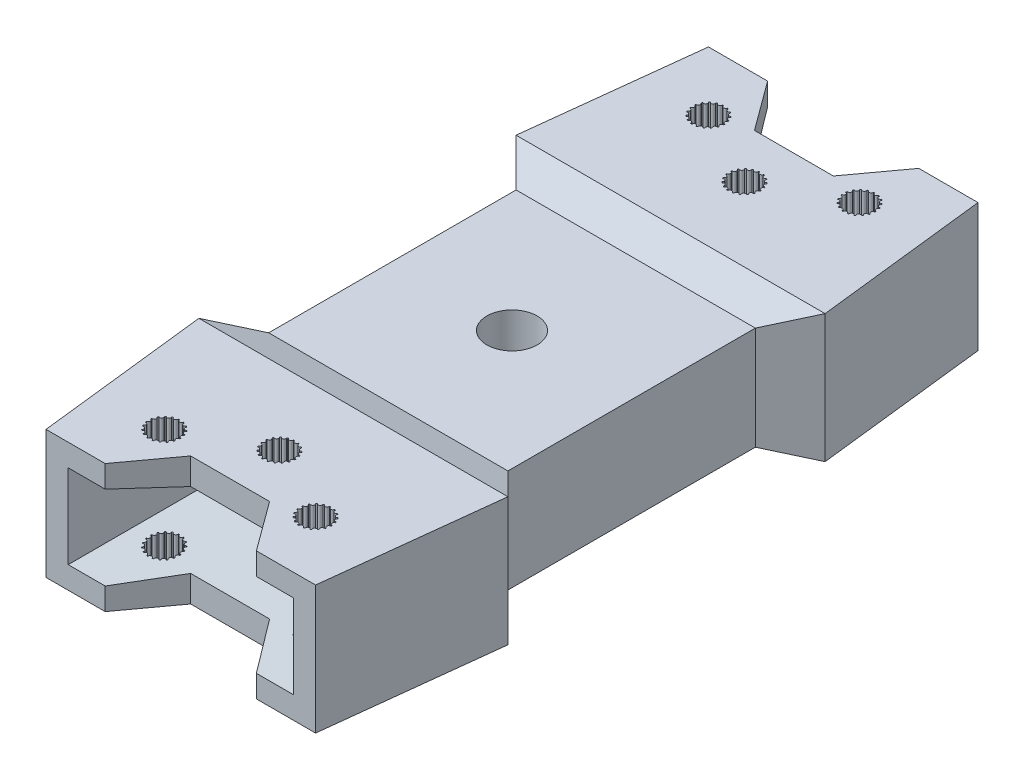
from build123d import *

# Parameters (mm, degrees)
SKETCH2_R           = 3
SKETCH2_R_2         = 5.1
BOSS_EXTRUDE1_DEPTH = 26
SKETCH3_W           = 70
SKETCH3_H           = 16
CUT_EXTRUDE1_DEPTH  = 27.5
CUT_EXTRUDE2_DEPTH  = 63
SKETCH9_R           = 2
CUT_EXTRUDE3_DEPTH  = 68
SKETCH10_W          = 45.651038986
SKETCH10_H          = 17
CUT_EXTRUDE4_DEPTH  = 28
CUT_EXTRUDE4_TAPER  = 5
SKETCH11_R          = 2
CUT_EXTRUDE5_DEPTH  = 54
SKETCH12_R          = 8.5
CUT_EXTRUDE6_DEPTH  = 10


with BuildPart() as part:
    # Sketch2 → Boss-Extrude1 (new body)
    with BuildSketch(Plane(origin=(0, 0, 0), x_dir=(1, 0, 0), z_dir=(0, 1, 0))):
        with BuildLine():
            ThreePointArc((15, 350), (0, 365), (-15, 350))
            Line((-15, 350), (-31.325519493, 207.151704434))
            Line((-31.325519493, 207.151704434), (-24.254451681, 200.080636622))
            Line((-24.254451681, 200.080636622), (-24.254451681, 149.919363378))
            Line((-24.254451681, 149.919363378), (-31.325519493, 142.848295566))
            Line((-31.325519493, 142.848295566), (-15, 0))
            ThreePointArc((-15, 0), (0, -15), (15, 0))
            Line((15, 0), (31.325519493, 142.848295566))
            Line((31.325519493, 142.848295566), (24.254451681, 149.919363378))
            Line((24.254451681, 149.919363378), (24.254451681, 200.080636622))
            Line((24.254451681, 200.080636622), (31.325519493, 207.151704434))
            Line((31.325519493, 207.151704434), (15, 350))
        make_face()
        Circle(SKETCH2_R, mode=Mode.SUBTRACT)
        with Locations((0, 175)):
            Circle(SKETCH2_R_2, mode=Mode.SUBTRACT)
        with Locations((0, 350)):
            Circle(SKETCH2_R, mode=Mode.SUBTRACT)
    extrude(amount=BOSS_EXTRUDE1_DEPTH)

    # Sketch3 → Cut-Extrude1 (cut, symmetric)
    with BuildSketch(Plane(origin=(0, 0, 0), x_dir=(0, 0, -1), z_dir=(1, 0, 0))):
        with Locations((-15, 13)):
            Rectangle(SKETCH3_W, SKETCH3_H)
    cut_extrude1 = extrude(amount=CUT_EXTRUDE1_DEPTH, both=True, mode=Mode.SUBTRACT)

    # Sketch5 → Cut-Extrude2 (cut, symmetric)
    with BuildSketch(Plane(origin=(24.254451681, 0, 0), x_dir=(0, 0, -1), z_dir=(1, 0, 0))):
        Polygon((142.848295566, 26), (149.919363378, 23.456766037), (200.080636622, 23.456766037), (207.151704434, 26), align=None)
        Polygon((207.151704434, 0), (200.080636622, 2.543233963), (149.919363378, 2.543233963), (142.848295566, 0), align=None)
    extrude(amount=CUT_EXTRUDE2_DEPTH, both=True, mode=Mode.SUBTRACT)

    # Mirror3: Cut-Extrude1 across plane
    add(cut_extrude1.mirror(Plane.XY.offset(-175)), mode=Mode.SUBTRACT)

    # Sketch9 → Cut-Extrude3 (cut, symmetric)
    with BuildSketch(Plane(origin=(0, 23.456766037, 0), x_dir=(1, 0, 0), z_dir=(0, 1, 0))):
        with Locations((0, 127.848295566)):
            Circle(SKETCH9_R)
        with Locations((-15.325519493, 119.848295566)):
            Circle(SKETCH9_R)
        with Locations((15.325519493, 119.848295566)):
            Circle(SKETCH9_R)
        Polygon((-27.325519493, 107.848295566), (-15.325519493, 107.848295566), (-8, 117.848295566), (8, 117.848295566), (15.325519493, 107.848295566), (27.325519493, 107.848295566), (32.660886482, 107.848295566), (15.941481629, -24.730405263), (-17.738358912, -19.447293022), (-31.029707264, 97.91851296), align=None)
    cut_extrude3 = extrude(amount=CUT_EXTRUDE3_DEPTH, both=True, mode=Mode.SUBTRACT)

    # Sketch10 → Cut-Extrude4 (cut)
    with BuildSketch(Plane.XY.offset(-107.848295566)):
        with Locations((0, 13)):
            Rectangle(SKETCH10_W, SKETCH10_H)
    cut_extrude4 = extrude(amount=-CUT_EXTRUDE4_DEPTH, taper=CUT_EXTRUDE4_TAPER, mode=Mode.SUBTRACT)

    # Mirror5: Cut-Extrude3, Cut-Extrude4 across plane
    add(cut_extrude3.mirror(Plane.XY.offset(-175)), mode=Mode.SUBTRACT)
    add(cut_extrude4.mirror(Plane.XY.offset(-175)), mode=Mode.SUBTRACT)

    # Sketch11 → Cut-Extrude5 (cut)
    with BuildSketch(Plane.XZ):
        with BuildLine():
            ThreePointArc((-12.078411866, -119.985379679), (-12.075519493, -119.848295566), (-12.078411866, -119.711211453))
            ThreePointArc((-12.078411866, -119.711211453), (-12.514389779, -119.379200984), (-12.209837975, -118.923617961))
            ThreePointArc((-12.209837975, -118.923617961), (-12.251613458, -118.793022291), (-12.298860252, -118.664304925))
            ThreePointArc((-12.298860252, -118.664304925), (-12.819019302, -118.491845496), (-12.678896521, -117.962059408))
            ThreePointArc((-12.678896521, -117.962059408), (-12.760812838, -117.85210425), (-12.847294131, -117.745702155))
            ThreePointArc((-12.847294131, -117.745702155), (-13.395267014, -117.751482421), (-13.434757733, -117.204903812))
            ThreePointArc((-13.434757733, -117.204903812), (-13.547937979, -117.127504512), (-13.664282181, -117.054948006))
            ThreePointArc((-13.664282181, -117.054948006), (-14.180687533, -117.238341585), (-14.39551232, -116.734200728))
            ThreePointArc((-14.39551232, -116.734200728), (-14.52769166, -116.697744702), (-14.661291071, -116.666896408))
            ThreePointArc((-14.661291071, -116.666896408), (-15.090168359, -117.008029761), (-15.457047615, -116.600958141))
            ThreePointArc((-15.457047615, -116.600958141), (-15.593902366, -116.609395964), (-15.730279417, -116.623598773))
            ThreePointArc((-15.730279417, -116.623598773), (-16.025153132, -117.085504808), (-16.504329796, -116.819614951))
            ThreePointArc((-16.504329796, -116.819614951), (-16.631029623, -116.872032254), (-16.755405745, -116.929747073))
            ThreePointArc((-16.755405745, -116.929747073), (-16.884321744, -117.462371103), (-17.423869591, -117.3664763))
            ThreePointArc((-17.423869591, -117.3664763), (-17.526684601, -117.457192856), (-17.62558171, -117.552165387))
            ThreePointArc((-17.62558171, -117.552165387), (-17.574569945, -118.097789335), (-18.116020593, -118.182281277))
            ThreePointArc((-18.116020593, -118.182281277), (-18.183809185, -118.301466539), (-18.246510245, -118.423405035))
            ThreePointArc((-18.246510245, -118.423405035), (-18.021098632, -118.922902079), (-18.505777502, -119.178624752))
            ThreePointArc((-18.505777502, -119.178624752), (-18.531193729, -119.313363148), (-18.550904109, -119.449053681))
            ThreePointArc((-18.550904109, -119.449053681), (-18.175519493, -119.848295566), (-18.550904109, -120.247537451))
            ThreePointArc((-18.550904109, -120.247537451), (-18.531193729, -120.383227984), (-18.505777502, -120.51796638))
            ThreePointArc((-18.505777502, -120.51796638), (-18.021098632, -120.773689053), (-18.246510245, -121.273186097))
            ThreePointArc((-18.246510245, -121.273186097), (-18.183809185, -121.395124593), (-18.116020593, -121.514309855))
            ThreePointArc((-18.116020593, -121.514309855), (-17.574569945, -121.598801797), (-17.62558171, -122.144425745))
            ThreePointArc((-17.62558171, -122.144425745), (-17.526684601, -122.239398276), (-17.423869591, -122.330114832))
            ThreePointArc((-17.423869591, -122.330114832), (-16.884321744, -122.234220029), (-16.755405745, -122.766844059))
            ThreePointArc((-16.755405745, -122.766844059), (-16.631029623, -122.824558878), (-16.504329796, -122.876976181))
            ThreePointArc((-16.504329796, -122.876976181), (-16.025153132, -122.611086324), (-15.730279417, -123.072992359))
            ThreePointArc((-15.730279417, -123.072992359), (-15.593902366, -123.087195168), (-15.457047615, -123.095632991))
            ThreePointArc((-15.457047615, -123.095632991), (-15.090168359, -122.688561371), (-14.661291071, -123.029694724))
            ThreePointArc((-14.661291071, -123.029694724), (-14.52769166, -122.99884643), (-14.39551232, -122.962390404))
            ThreePointArc((-14.39551232, -122.962390404), (-14.180687533, -122.458249547), (-13.664282181, -122.641643126))
            ThreePointArc((-13.664282181, -122.641643126), (-13.547937979, -122.56908662), (-13.434757733, -122.49168732))
            ThreePointArc((-13.434757733, -122.49168732), (-13.395267014, -121.945108711), (-12.847294131, -121.950888977))
            ThreePointArc((-12.847294131, -121.950888977), (-12.760812838, -121.844486882), (-12.678896521, -121.734531724))
            ThreePointArc((-12.678896521, -121.734531724), (-12.819019302, -121.204745636), (-12.298860252, -121.032286207))
            ThreePointArc((-12.298860252, -121.032286207), (-12.251613458, -120.903568841), (-12.209837975, -120.772973171))
            ThreePointArc((-12.209837975, -120.772973171), (-12.514389779, -120.317390148), (-12.078411866, -119.985379679))
        make_face()
        with Locations((-15.325519493, -119.848295566)):
            Circle(SKETCH11_R, mode=Mode.SUBTRACT)
        with BuildLine():
            ThreePointArc((3.247107628, -127.985379679), (3.25, -127.848295566), (3.247107628, -127.711211453))
            ThreePointArc((3.247107628, -127.711211453), (2.811129715, -127.379200984), (3.115681519, -126.923617961))
            ThreePointArc((3.115681519, -126.923617961), (3.073906036, -126.793022291), (3.026659241, -126.664304925))
            ThreePointArc((3.026659241, -126.664304925), (2.506500191, -126.491845496), (2.646622972, -125.962059408))
            ThreePointArc((2.646622972, -125.962059408), (2.564706656, -125.85210425), (2.478225362, -125.745702155))
            ThreePointArc((2.478225362, -125.745702155), (1.930252479, -125.751482421), (1.89076176, -125.204903812))
            ThreePointArc((1.89076176, -125.204903812), (1.777581514, -125.127504512), (1.661237312, -125.054948006))
            ThreePointArc((1.661237312, -125.054948006), (1.14483196, -125.238341585), (0.930007173, -124.734200728))
            ThreePointArc((0.930007173, -124.734200728), (0.797827833, -124.697744702), (0.664228422, -124.666896408))
            ThreePointArc((0.664228422, -124.666896408), (0.235351135, -125.008029761), (-0.131528121, -124.600958141))
            ThreePointArc((-0.131528121, -124.600958141), (-0.268382873, -124.609395964), (-0.404759924, -124.623598773))
            ThreePointArc((-0.404759924, -124.623598773), (-0.699633638, -125.085504808), (-1.178810303, -124.819614951))
            ThreePointArc((-1.178810303, -124.819614951), (-1.30551013, -124.872032254), (-1.429886252, -124.929747073))
            ThreePointArc((-1.429886252, -124.929747073), (-1.558802251, -125.462371103), (-2.098350098, -125.3664763))
            ThreePointArc((-2.098350098, -125.3664763), (-2.201165108, -125.457192856), (-2.300062217, -125.552165387))
            ThreePointArc((-2.300062217, -125.552165387), (-2.249050452, -126.097789335), (-2.7905011, -126.182281277))
            ThreePointArc((-2.7905011, -126.182281277), (-2.858289691, -126.301466539), (-2.920990752, -126.423405035))
            ThreePointArc((-2.920990752, -126.423405035), (-2.695579139, -126.922902079), (-3.180258009, -127.178624752))
            ThreePointArc((-3.180258009, -127.178624752), (-3.205674236, -127.313363148), (-3.225384615, -127.449053681))
            ThreePointArc((-3.225384615, -127.449053681), (-2.85, -127.848295566), (-3.225384615, -128.247537451))
            ThreePointArc((-3.225384615, -128.247537451), (-3.205674236, -128.383227984), (-3.180258009, -128.51796638))
            ThreePointArc((-3.180258009, -128.51796638), (-2.695579139, -128.773689053), (-2.920990752, -129.273186097))
            ThreePointArc((-2.920990752, -129.273186097), (-2.858289691, -129.395124593), (-2.7905011, -129.514309855))
            ThreePointArc((-2.7905011, -129.514309855), (-2.249050452, -129.598801797), (-2.300062217, -130.144425745))
            ThreePointArc((-2.300062217, -130.144425745), (-2.201165108, -130.239398276), (-2.098350098, -130.330114832))
            ThreePointArc((-2.098350098, -130.330114832), (-1.558802251, -130.234220029), (-1.429886252, -130.766844059))
            ThreePointArc((-1.429886252, -130.766844059), (-1.30551013, -130.824558878), (-1.178810303, -130.876976181))
            ThreePointArc((-1.178810303, -130.876976181), (-0.699633638, -130.611086324), (-0.404759924, -131.072992359))
            ThreePointArc((-0.404759924, -131.072992359), (-0.268382873, -131.087195168), (-0.131528121, -131.095632991))
            ThreePointArc((-0.131528121, -131.095632991), (0.235351135, -130.688561371), (0.664228422, -131.029694724))
            ThreePointArc((0.664228422, -131.029694724), (0.797827833, -130.99884643), (0.930007173, -130.962390404))
            ThreePointArc((0.930007173, -130.962390404), (1.14483196, -130.458249547), (1.661237312, -130.641643126))
            ThreePointArc((1.661237312, -130.641643126), (1.777581514, -130.56908662), (1.89076176, -130.49168732))
            ThreePointArc((1.89076176, -130.49168732), (1.930252479, -129.945108711), (2.478225362, -129.950888977))
            ThreePointArc((2.478225362, -129.950888977), (2.564706656, -129.844486882), (2.646622972, -129.734531724))
            ThreePointArc((2.646622972, -129.734531724), (2.506500191, -129.204745636), (3.026659241, -129.032286207))
            ThreePointArc((3.026659241, -129.032286207), (3.073906036, -128.903568841), (3.115681519, -128.772973171))
            ThreePointArc((3.115681519, -128.772973171), (2.811129715, -128.317390148), (3.247107628, -127.985379679))
        make_face()
        with Locations((0, -127.848295566)):
            Circle(SKETCH11_R, mode=Mode.SUBTRACT)
        with BuildLine():
            ThreePointArc((18.572627121, -119.985379679), (18.575519493, -119.848295566), (18.572627121, -119.711211453))
            ThreePointArc((18.572627121, -119.711211453), (18.136649208, -119.379200984), (18.441201012, -118.923617961))
            ThreePointArc((18.441201012, -118.923617961), (18.399425529, -118.793022291), (18.352178734, -118.664304925))
            ThreePointArc((18.352178734, -118.664304925), (17.832019684, -118.491845496), (17.972142466, -117.962059408))
            ThreePointArc((17.972142466, -117.962059408), (17.890226149, -117.85210425), (17.803744856, -117.745702155))
            ThreePointArc((17.803744856, -117.745702155), (17.255771972, -117.751482421), (17.216281254, -117.204903812))
            ThreePointArc((17.216281254, -117.204903812), (17.103101007, -117.127504512), (16.986756805, -117.054948006))
            ThreePointArc((16.986756805, -117.054948006), (16.470351454, -117.238341585), (16.255526667, -116.734200728))
            ThreePointArc((16.255526667, -116.734200728), (16.123347326, -116.697744702), (15.989747915, -116.666896408))
            ThreePointArc((15.989747915, -116.666896408), (15.560870628, -117.008029761), (15.193991372, -116.600958141))
            ThreePointArc((15.193991372, -116.600958141), (15.05713662, -116.609395964), (14.920759569, -116.623598773))
            ThreePointArc((14.920759569, -116.623598773), (14.625885855, -117.085504808), (14.14670919, -116.819614951))
            ThreePointArc((14.14670919, -116.819614951), (14.020009363, -116.872032254), (13.895633242, -116.929747073))
            ThreePointArc((13.895633242, -116.929747073), (13.766717243, -117.462371103), (13.227169396, -117.3664763))
            ThreePointArc((13.227169396, -117.3664763), (13.124354385, -117.457192856), (13.025457276, -117.552165387))
            ThreePointArc((13.025457276, -117.552165387), (13.076469041, -118.097789335), (12.535018394, -118.182281277))
            ThreePointArc((12.535018394, -118.182281277), (12.467229802, -118.301466539), (12.404528741, -118.423405035))
            ThreePointArc((12.404528741, -118.423405035), (12.629940354, -118.922902079), (12.145261485, -119.178624752))
            ThreePointArc((12.145261485, -119.178624752), (12.119845257, -119.313363148), (12.100134878, -119.449053681))
            ThreePointArc((12.100134878, -119.449053681), (12.475519493, -119.848295566), (12.100134878, -120.247537451))
            ThreePointArc((12.100134878, -120.247537451), (12.119845257, -120.383227984), (12.145261485, -120.51796638))
            ThreePointArc((12.145261485, -120.51796638), (12.629940354, -120.773689053), (12.404528741, -121.273186097))
            ThreePointArc((12.404528741, -121.273186097), (12.467229802, -121.395124593), (12.535018394, -121.514309855))
            ThreePointArc((12.535018394, -121.514309855), (13.076469041, -121.598801797), (13.025457276, -122.144425745))
            ThreePointArc((13.025457276, -122.144425745), (13.124354385, -122.239398276), (13.227169396, -122.330114832))
            ThreePointArc((13.227169396, -122.330114832), (13.766717243, -122.234220029), (13.895633242, -122.766844059))
            ThreePointArc((13.895633242, -122.766844059), (14.020009363, -122.824558878), (14.14670919, -122.876976181))
            ThreePointArc((14.14670919, -122.876976181), (14.625885855, -122.611086324), (14.920759569, -123.072992359))
            ThreePointArc((14.920759569, -123.072992359), (15.05713662, -123.087195168), (15.193991372, -123.095632991))
            ThreePointArc((15.193991372, -123.095632991), (15.560870628, -122.688561371), (15.989747915, -123.029694724))
            ThreePointArc((15.989747915, -123.029694724), (16.123347326, -122.99884643), (16.255526667, -122.962390404))
            ThreePointArc((16.255526667, -122.962390404), (16.470351454, -122.458249547), (16.986756805, -122.641643126))
            ThreePointArc((16.986756805, -122.641643126), (17.103101007, -122.56908662), (17.216281254, -122.49168732))
            ThreePointArc((17.216281254, -122.49168732), (17.255771972, -121.945108711), (17.803744856, -121.950888977))
            ThreePointArc((17.803744856, -121.950888977), (17.890226149, -121.844486882), (17.972142466, -121.734531724))
            ThreePointArc((17.972142466, -121.734531724), (17.832019684, -121.204745636), (18.352178734, -121.032286207))
            ThreePointArc((18.352178734, -121.032286207), (18.399425529, -120.903568841), (18.441201012, -120.772973171))
            ThreePointArc((18.441201012, -120.772973171), (18.136649208, -120.317390148), (18.572627121, -119.985379679))
        make_face()
        with Locations((15.325519493, -119.848295566)):
            Circle(SKETCH11_R, mode=Mode.SUBTRACT)
    cut_extrude5 = extrude(amount=-CUT_EXTRUDE5_DEPTH, mode=Mode.SUBTRACT)

    # Mirror6: Cut-Extrude5 across plane
    add(cut_extrude5.mirror(Plane.XY.offset(-175)), mode=Mode.SUBTRACT)

    # Sketch12 → Cut-Extrude6 (cut)
    with BuildSketch(Plane.XZ.offset(-2.543233963)):
        with Locations((0, -175)):
            Circle(SKETCH12_R)
    extrude(amount=-CUT_EXTRUDE6_DEPTH, mode=Mode.SUBTRACT)


solid = part.part
